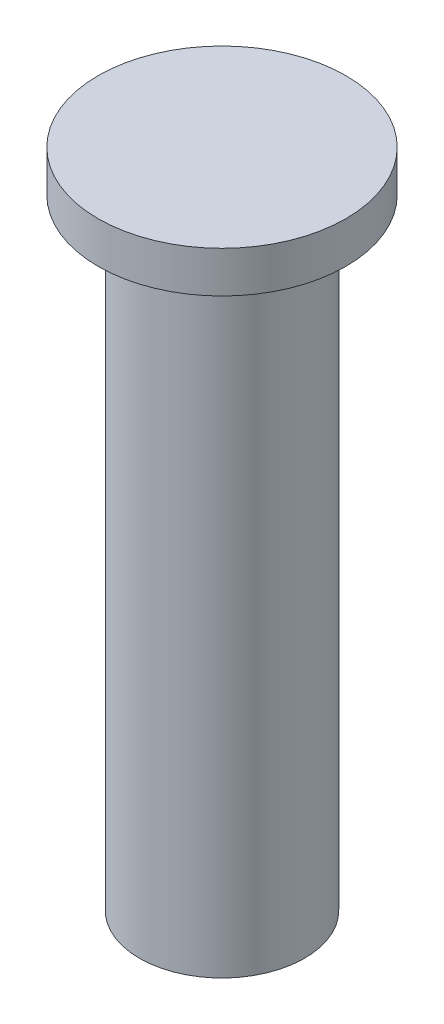
from build123d import *

# Parameters (mm, degrees)
SKETCH1_R           = 5.075
BOSS_EXTRUDE1_DEPTH = 38.1
SKETCH2_R           = 7.615
BOSS_EXTRUDE2_DEPTH = 2.54


with BuildPart() as part:
    # Sketch1 → Boss-Extrude1 (new body)
    with BuildSketch(Plane(origin=(0, 0, 0), x_dir=(1, 0, 0), z_dir=(0, 1, 0))):
        Circle(SKETCH1_R)
    extrude(amount=BOSS_EXTRUDE1_DEPTH)

    # Sketch2 → Boss-Extrude2 (add)
    with BuildSketch(Plane(origin=(0, 38.1, 0), x_dir=(1, 0, 0), z_dir=(0, 1, 0))):
        Circle(SKETCH2_R)
    extrude(amount=BOSS_EXTRUDE2_DEPTH)


solid = part.part
